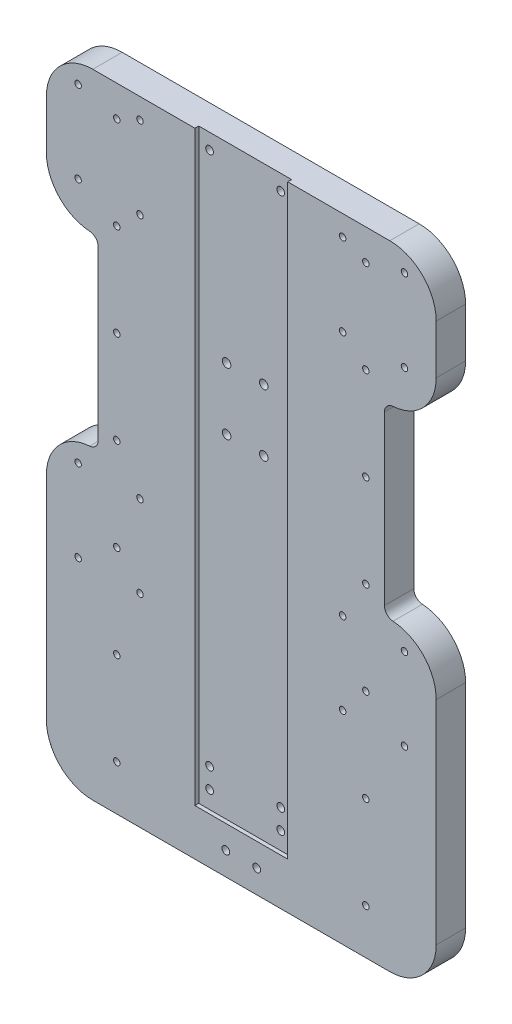
from build123d import *

# Parameters (mm, degrees)
SCHIZZO1_W                       = 252
SCHIZZO1_H                       = 500
ESTRUSIONE_ESTRUSIONE1_DEPTH     = 19
SCHIZZO3_W                       = 60
SCHIZZO3_H                       = 2.5
TAGLIO_ESTRUSIONE1_DEPTH         = 501
TAP_DRILL_FOR_M5_TAP2_AT_2_COUNT = 2
TAP_DRILL_FOR_M5_TAP2_AT_2_PITCH = 60
TAP_DRILL_FOR_M5_TAP2_AT_3_COUNT = 2
TAP_DRILL_FOR_M5_TAP2_AT_3_PITCH = 120
TAP_DRILL_FOR_M5_TAP2_AT_4_COUNT = 2
TAP_DRILL_FOR_M5_TAP2_AT_4_PITCH = 180
TAP_DRILL_FOR_M5_TAP2_AT_5_COUNT = 2
TAP_DRILL_FOR_M5_TAP2_AT_5_PITCH = 240
TAP_DRILL_FOR_M5_TAP2_AT_6_COUNT = 2
TAP_DRILL_FOR_M5_TAP2_AT_6_PITCH = 300
TAP_DRILL_FOR_M5_TAP2_AT_7_COUNT = 2
TAP_DRILL_FOR_M5_TAP2_AT_7_PITCH = 360
TAP_DRILL_FOR_M5_TAP1_AT_2_COUNT = 2
TAP_DRILL_FOR_M5_TAP1_AT_2_PITCH = 40
TAP_DRILL_FOR_M5_TAP1_AT_3_COUNT = 2
TAP_DRILL_FOR_M5_TAP1_AT_3_PITCH = 53
TAP_DRILL_FOR_M5_TAP1_AT_4_COUNT = 2
TAP_DRILL_FOR_M5_TAP1_AT_4_PITCH = 66.400301204
TAP_DRILL_FOR_M5_TAP1_AT_5_COUNT = 2
TAP_DRILL_FOR_M5_TAP1_AT_5_PITCH = 265.000000001
TAP_DRILL_FOR_M5_TAP1_AT_6_COUNT = 2
TAP_DRILL_FOR_M5_TAP1_AT_6_PITCH = 268.001865666
TAP_DRILL_FOR_M5_TAP1_AT_7_COUNT = 2
TAP_DRILL_FOR_M5_TAP1_AT_7_PITCH = 215.740584963
TAP_DRILL_FOR_M5_TAP1_AT_8_COUNT = 2
TAP_DRILL_FOR_M5_TAP1_AT_8_PITCH = 212.000000001
TAP_DRILL_FOR_M6_TAP4_D          = 5
TAP_DRILL_FOR_M6_TAP4_DEPTH      = 36.6
TAP_DRILL_FOR_M6_TAP4_TIP        = 1.502151548
SKETCH16_W                       = 252
SKETCH16_H                       = 158.679931771
CUT_EXTRUDE1_DEPTH               = 28
SKETCH26_W                       = 60
SKETCH26_H                       = 30
BOSS_EXTRUDE1_DEPTH              = 2.5
M5_CLEARANCE_HOLE1_D             = 5.5
TAP_DRILL_FOR_M6_TAP2_D          = 5
TAP_DRILL_FOR_M6_TAP2_DEPTH      = 30
TAP_DRILL_FOR_M6_TAP2_TIP        = 1.502151548
TAP_DRILL_FOR_M6_TAP3_D          = 5
SKETCH27_W                       = 33.5
SKETCH27_H                       = 120.140011943
CUT_EXTRUDE2_DEPTH               = 76.991082214
FILLET1_R                        = 30
FILLET2_R                        = 30
FILLET3_R                        = 6
SKETCH28_W                       = 64
SKETCH28_H                       = 56
CUT_EXTRUDE3_DEPTH               = 2


with BuildPart() as part:
    # Schizzo1 → Estrusione-Estrusione1 (new body)
    with BuildSketch(Plane.XY):
        Rectangle(SCHIZZO1_W, SCHIZZO1_H)
    extrude(amount=ESTRUSIONE_ESTRUSIONE1_DEPTH)

    # Schizzo3 → Taglio-Estrusione1 (cut, through all)
    with BuildSketch(Plane(origin=(0, 250, 0), x_dir=(1, 0, 0), z_dir=(0, 1, 0))):
        with Locations((0, -17.75)):
            Rectangle(SCHIZZO3_W, SCHIZZO3_H)
    extrude(amount=-TAGLIO_ESTRUSIONE1_DEPTH, mode=Mode.SUBTRACT)

    # Sketch8 → Tap Drill for M5 Tap2 (revolve, cut)
    with BuildSketch(Plane(origin=(80.500605801, -130, 19), x_dir=(0, -1, 0), z_dir=(1, 0, 0))):
        Polygon((0, 0), (0, 37.8618073), (2.1, 36.6), (2.1, 0), align=None)
    tap_drill_for_m5_tap2 = revolve(axis=Axis((80.500605801, -130, 25.35), (0, 0, -1)), mode=Mode.SUBTRACT)

    # Tap Drill for M5 Tap2 at 2: Tap Drill for M5 Tap2 ×2
    with Locations(*[(0, i * TAP_DRILL_FOR_M5_TAP2_AT_2_PITCH, 0) for i in range(1, TAP_DRILL_FOR_M5_TAP2_AT_2_COUNT)]):
        add(tap_drill_for_m5_tap2, mode=Mode.SUBTRACT)

    # Tap Drill for M5 Tap2 at 3: Tap Drill for M5 Tap2 ×2
    with Locations(*[(0, i * TAP_DRILL_FOR_M5_TAP2_AT_3_PITCH, 0) for i in range(1, TAP_DRILL_FOR_M5_TAP2_AT_3_COUNT)]):
        add(tap_drill_for_m5_tap2, mode=Mode.SUBTRACT)

    # Tap Drill for M5 Tap2 at 4: Tap Drill for M5 Tap2 ×2
    with Locations(*[(0, i * TAP_DRILL_FOR_M5_TAP2_AT_4_PITCH, 0) for i in range(1, TAP_DRILL_FOR_M5_TAP2_AT_4_COUNT)]):
        add(tap_drill_for_m5_tap2, mode=Mode.SUBTRACT)

    # Tap Drill for M5 Tap2 at 5: Tap Drill for M5 Tap2 ×2
    with Locations(*[(0, i * TAP_DRILL_FOR_M5_TAP2_AT_5_PITCH, 0) for i in range(1, TAP_DRILL_FOR_M5_TAP2_AT_5_COUNT)]):
        add(tap_drill_for_m5_tap2, mode=Mode.SUBTRACT)

    # Tap Drill for M5 Tap2 at 6: Tap Drill for M5 Tap2 ×2
    with Locations(*[(0, i * TAP_DRILL_FOR_M5_TAP2_AT_6_PITCH, 0) for i in range(1, TAP_DRILL_FOR_M5_TAP2_AT_6_COUNT)]):
        add(tap_drill_for_m5_tap2, mode=Mode.SUBTRACT)

    # Tap Drill for M5 Tap2 at 7: Tap Drill for M5 Tap2 ×2
    with Locations(*[(0, i * TAP_DRILL_FOR_M5_TAP2_AT_7_PITCH, 0) for i in range(1, TAP_DRILL_FOR_M5_TAP2_AT_7_COUNT)]):
        add(tap_drill_for_m5_tap2, mode=Mode.SUBTRACT)

    # Sketch15 → Tap Drill for M5 Tap1 (revolve, cut)
    with BuildSketch(Plane(origin=(105.5, 236.808299653, 19), x_dir=(0, -1, 0), z_dir=(1, 0, 0))):
        Polygon((0, 0), (0, 37.8618073), (2.1, 36.6), (2.1, 0), align=None)
    tap_drill_for_m5_tap1 = revolve(axis=Axis((105.5, 236.808299653, 25.35), (0, 0, -1)), mode=Mode.SUBTRACT)

    # Tap Drill for M5 Tap1 at 2: Tap Drill for M5 Tap1 ×2
    with Locations(*[(-i * TAP_DRILL_FOR_M5_TAP1_AT_2_PITCH, 0, 0) for i in range(1, TAP_DRILL_FOR_M5_TAP1_AT_2_COUNT)]):
        add(tap_drill_for_m5_tap1, mode=Mode.SUBTRACT)

    # Tap Drill for M5 Tap1 at 3: Tap Drill for M5 Tap1 ×2
    with Locations(*[(0, -i * TAP_DRILL_FOR_M5_TAP1_AT_3_PITCH, 0) for i in range(1, TAP_DRILL_FOR_M5_TAP1_AT_3_COUNT)]):
        add(tap_drill_for_m5_tap1, mode=Mode.SUBTRACT)

    # Tap Drill for M5 Tap1 at 4: Tap Drill for M5 Tap1 ×2
    with Locations(*[Vector(-0.602406906, -0.79818915, 0) * (i * TAP_DRILL_FOR_M5_TAP1_AT_4_PITCH) for i in range(1, TAP_DRILL_FOR_M5_TAP1_AT_4_COUNT)]):
        add(tap_drill_for_m5_tap1, mode=Mode.SUBTRACT)

    # Tap Drill for M5 Tap1 at 5: Tap Drill for M5 Tap1 ×2
    with Locations(*[(0, -i * TAP_DRILL_FOR_M5_TAP1_AT_5_PITCH, 0) for i in range(1, TAP_DRILL_FOR_M5_TAP1_AT_5_COUNT)]):
        add(tap_drill_for_m5_tap1, mode=Mode.SUBTRACT)

    # Tap Drill for M5 Tap1 at 6: Tap Drill for M5 Tap1 ×2
    with Locations(*[Vector(-0.149252692, -0.988799087, 0) * (i * TAP_DRILL_FOR_M5_TAP1_AT_6_PITCH) for i in range(1, TAP_DRILL_FOR_M5_TAP1_AT_6_COUNT)]):
        add(tap_drill_for_m5_tap1, mode=Mode.SUBTRACT)

    # Tap Drill for M5 Tap1 at 7: Tap Drill for M5 Tap1 ×2
    with Locations(*[Vector(-0.185407859, -0.982661654, 0) * (i * TAP_DRILL_FOR_M5_TAP1_AT_7_PITCH) for i in range(1, TAP_DRILL_FOR_M5_TAP1_AT_7_COUNT)]):
        add(tap_drill_for_m5_tap1, mode=Mode.SUBTRACT)

    # Tap Drill for M5 Tap1 at 8: Tap Drill for M5 Tap1 ×2
    with Locations(*[(0, -i * TAP_DRILL_FOR_M5_TAP1_AT_8_PITCH, 0) for i in range(1, TAP_DRILL_FOR_M5_TAP1_AT_8_COUNT)]):
        add(tap_drill_for_m5_tap1, mode=Mode.SUBTRACT)

    # Tap Drill for M6 Tap4
    with Locations(Plane.XY.offset(16.5)):
        with Locations((23, -118), (23, -105), (-23, -118), (-23, -105), (23, 240), (-23, 240)):
            Hole(TAP_DRILL_FOR_M6_TAP4_D / 2, depth=TAP_DRILL_FOR_M6_TAP4_DEPTH)
            with Locations((0, 0, -(TAP_DRILL_FOR_M6_TAP4_DEPTH + TAP_DRILL_FOR_M6_TAP4_TIP / 2))):  # 118° drill point
                Cone(0, TAP_DRILL_FOR_M6_TAP4_D / 2, TAP_DRILL_FOR_M6_TAP4_TIP, mode=Mode.SUBTRACT)

    # Mirror1: Tap Drill for M5 Tap2 across plane
    add(tap_drill_for_m5_tap2.mirror(Plane.ZY), mode=Mode.SUBTRACT)

    # Mirror1 copy 1 sketch → Mirror1 copy 1 (revolve, cut)
    with BuildSketch(Plane(origin=(-80.500605801, -70, 19), x_dir=(0, -1, 0), z_dir=(-1, 0, 0))):
        Polygon((0, 0), (0, -37.8618073), (2.1, -36.6), (2.1, 0), align=None)
    revolve(axis=Axis((-80.500605801, -70, 25.35), (0, 0, 1)), mode=Mode.SUBTRACT)

    # Mirror1 copy 2 sketch → Mirror1 copy 2 (revolve, cut)
    with BuildSketch(Plane(origin=(-80.500605801, -10, 19), x_dir=(0, -1, 0), z_dir=(-1, 0, 0))):
        Polygon((0, 0), (0, -37.8618073), (2.1, -36.6), (2.1, 0), align=None)
    revolve(axis=Axis((-80.500605801, -10, 25.35), (0, 0, 1)), mode=Mode.SUBTRACT)

    # Mirror1 copy 3 sketch → Mirror1 copy 3 (revolve, cut)
    with BuildSketch(Plane(origin=(-80.500605801, 50, 19), x_dir=(0, -1, 0), z_dir=(-1, 0, 0))):
        Polygon((0, 0), (0, -37.8618073), (2.1, -36.6), (2.1, 0), align=None)
    revolve(axis=Axis((-80.500605801, 50, 25.35), (0, 0, 1)), mode=Mode.SUBTRACT)

    # Mirror1 copy 4 sketch → Mirror1 copy 4 (revolve, cut)
    with BuildSketch(Plane(origin=(-80.500605801, 110, 19), x_dir=(0, -1, 0), z_dir=(-1, 0, 0))):
        Polygon((0, 0), (0, -37.8618073), (2.1, -36.6), (2.1, 0), align=None)
    revolve(axis=Axis((-80.500605801, 110, 25.35), (0, 0, 1)), mode=Mode.SUBTRACT)

    # Mirror1 copy 5 sketch → Mirror1 copy 5 (revolve, cut)
    with BuildSketch(Plane(origin=(-80.500605801, 170, 19), x_dir=(0, -1, 0), z_dir=(-1, 0, 0))):
        Polygon((0, 0), (0, -37.8618073), (2.1, -36.6), (2.1, 0), align=None)
    revolve(axis=Axis((-80.500605801, 170, 25.35), (0, 0, 1)), mode=Mode.SUBTRACT)

    # Mirror1 copy 6 sketch → Mirror1 copy 6 (revolve, cut)
    with BuildSketch(Plane(origin=(-80.500605801, 230, 19), x_dir=(0, -1, 0), z_dir=(-1, 0, 0))):
        Polygon((0, 0), (0, -37.8618073), (2.1, -36.6), (2.1, 0), align=None)
    revolve(axis=Axis((-80.500605801, 230, 25.35), (0, 0, 1)), mode=Mode.SUBTRACT)

    # Mirror2: Tap Drill for M5 Tap1 across plane
    add(tap_drill_for_m5_tap1.mirror(Plane.ZY), mode=Mode.SUBTRACT)

    # Mirror2 copy 1 sketch → Mirror2 copy 1 (revolve, cut)
    with BuildSketch(Plane(origin=(-65.5, 236.808299653, 19), x_dir=(0, -1, 0), z_dir=(-1, 0, 0))):
        Polygon((0, 0), (0, -37.8618073), (2.1, -36.6), (2.1, 0), align=None)
    revolve(axis=Axis((-65.5, 236.808299653, 25.35), (0, 0, 1)), mode=Mode.SUBTRACT)

    # Mirror2 copy 2 sketch → Mirror2 copy 2 (revolve, cut)
    with BuildSketch(Plane(origin=(-105.5, 183.808299653, 19), x_dir=(0, -1, 0), z_dir=(-1, 0, 0))):
        Polygon((0, 0), (0, -37.8618073), (2.1, -36.6), (2.1, 0), align=None)
    revolve(axis=Axis((-105.5, 183.808299653, 25.35), (0, 0, 1)), mode=Mode.SUBTRACT)

    # Mirror2 copy 3 sketch → Mirror2 copy 3 (revolve, cut)
    with BuildSketch(Plane(origin=(-65.5, 183.808299653, 19), x_dir=(0, -1, 0), z_dir=(-1, 0, 0))):
        Polygon((0, 0), (0, -37.8618073), (2.1, -36.6), (2.1, 0), align=None)
    revolve(axis=Axis((-65.5, 183.808299653, 25.35), (0, 0, 1)), mode=Mode.SUBTRACT)

    # Mirror2 copy 4 sketch → Mirror2 copy 4 (revolve, cut)
    with BuildSketch(Plane(origin=(-105.5, -28.191700348, 19), x_dir=(0, -1, 0), z_dir=(-1, 0, 0))):
        Polygon((0, 0), (0, -37.8618073), (2.1, -36.6), (2.1, 0), align=None)
    revolve(axis=Axis((-105.5, -28.191700348, 25.35), (0, 0, 1)), mode=Mode.SUBTRACT)

    # Mirror2 copy 5 sketch → Mirror2 copy 5 (revolve, cut)
    with BuildSketch(Plane(origin=(-65.5, -28.191700348, 19), x_dir=(0, -1, 0), z_dir=(-1, 0, 0))):
        Polygon((0, 0), (0, -37.8618073), (2.1, -36.6), (2.1, 0), align=None)
    revolve(axis=Axis((-65.5, -28.191700348, 25.35), (0, 0, 1)), mode=Mode.SUBTRACT)

    # Mirror2 copy 6 sketch → Mirror2 copy 6 (revolve, cut)
    with BuildSketch(Plane(origin=(-65.5, 24.808299652, 19), x_dir=(0, -1, 0), z_dir=(-1, 0, 0))):
        Polygon((0, 0), (0, -37.8618073), (2.1, -36.6), (2.1, 0), align=None)
    revolve(axis=Axis((-65.5, 24.808299652, 25.35), (0, 0, 1)), mode=Mode.SUBTRACT)

    # Mirror2 copy 7 sketch → Mirror2 copy 7 (revolve, cut)
    with BuildSketch(Plane(origin=(-105.5, 24.808299652, 19), x_dir=(0, -1, 0), z_dir=(-1, 0, 0))):
        Polygon((0, 0), (0, -37.8618073), (2.1, -36.6), (2.1, 0), align=None)
    revolve(axis=Axis((-105.5, 24.808299652, 25.35), (0, 0, 1)), mode=Mode.SUBTRACT)

    # Sketch16 → Cut-Extrude1 (cut)
    with BuildSketch(Plane(origin=(0, 0, 0), x_dir=(-1, 0, 0), z_dir=(0, 0, -1))):
        with Locations((0, -238.589965886)):
            Rectangle(SKETCH16_W, SKETCH16_H)
    extrude(amount=-CUT_EXTRUDE1_DEPTH, mode=Mode.SUBTRACT)

    # Sketch26 → Boss-Extrude1 (add)
    with BuildSketch(Plane.XY.offset(16.5)):
        with Locations((0, -144.25)):
            Rectangle(SKETCH26_W, SKETCH26_H)
    extrude(amount=BOSS_EXTRUDE1_DEPTH)

    # M5 Clearance Hole1 (through all)
    with Locations(Plane.XY.offset(16.5)):
        with Locations((-12, 86.308299651), (12, 86.308299651), (12, 126.308299651), (-12, 126.308299651)):
            Hole(M5_CLEARANCE_HOLE1_D / 2)

    # Tap Drill for M6 Tap2
    with Locations(Plane(origin=(0, -159.25, 0), x_dir=(-1, 0, 0), z_dir=(0, -1, 0))):
        with Locations((20, -7.125), (-20, -7.125)):
            Hole(TAP_DRILL_FOR_M6_TAP2_D / 2, depth=TAP_DRILL_FOR_M6_TAP2_DEPTH)
            with Locations((0, 0, -(TAP_DRILL_FOR_M6_TAP2_DEPTH + TAP_DRILL_FOR_M6_TAP2_TIP / 2))):  # 118° drill point
                Cone(0, TAP_DRILL_FOR_M6_TAP2_D / 2, TAP_DRILL_FOR_M6_TAP2_TIP, mode=Mode.SUBTRACT)

    # Tap Drill for M6 Tap3 (through all)
    with Locations(Plane(origin=(0, 0, 0), x_dir=(-1, 0, 0), z_dir=(0, 0, -1))):
        with Locations((-10, -144.25), (10, -144.25)):
            Hole(TAP_DRILL_FOR_M6_TAP3_D / 2)

    # Sketch27 → Cut-Extrude2 (cut)
    with BuildSketch(Plane.XY.offset(19)):
        with Locations((109.25, 98.152026033)):
            Rectangle(SKETCH27_W, SKETCH27_H)
        with Locations((-109.25, 98.152026033)):
            Rectangle(SKETCH27_W, SKETCH27_H)
    extrude(amount=-CUT_EXTRUDE2_DEPTH, mode=Mode.SUBTRACT)

    # Fillet1
    fillet1_edges = [part.edges().sort_by_distance(p)[0] for p in [
        (126, 158.222032004, 9.5),
        (126, 38.082020061, 9.5),
        (-126, 158.222032004, 9.5),
        (-126, 38.082020061, 9.5),
    ]]
    fillet(fillet1_edges, radius=FILLET1_R)

    # Fillet2
    fillet2_edges = [part.edges().sort_by_distance(p)[0] for p in [
        (-126, -159.25, 9.5),
        (126, -159.25, 9.5),
        (-126, 250, 9.5),
        (126, 250, 9.5),
    ]]
    fillet(fillet2_edges, radius=FILLET2_R)

    # Fillet3
    fillet3_edges = [part.edges().sort_by_distance(p)[0] for p in [
        (92.5, 158.222032004, 9.5),
        (92.5, 38.082020061, 9.5),
        (-92.5, 38.082020061, 9.5),
        (-92.5, 158.222032004, 9.5),
    ]]
    fillet(fillet3_edges, radius=FILLET3_R)

    # Sketch28 → Cut-Extrude3 (cut)
    with BuildSketch(Plane(origin=(0, 0, 0), x_dir=(-1, 0, 0), z_dir=(0, 0, -1))):
        with Locations((0, 106.308299651)):
            Rectangle(SKETCH28_W, SKETCH28_H)
    extrude(amount=-CUT_EXTRUDE3_DEPTH, mode=Mode.SUBTRACT)


solid = part.part
